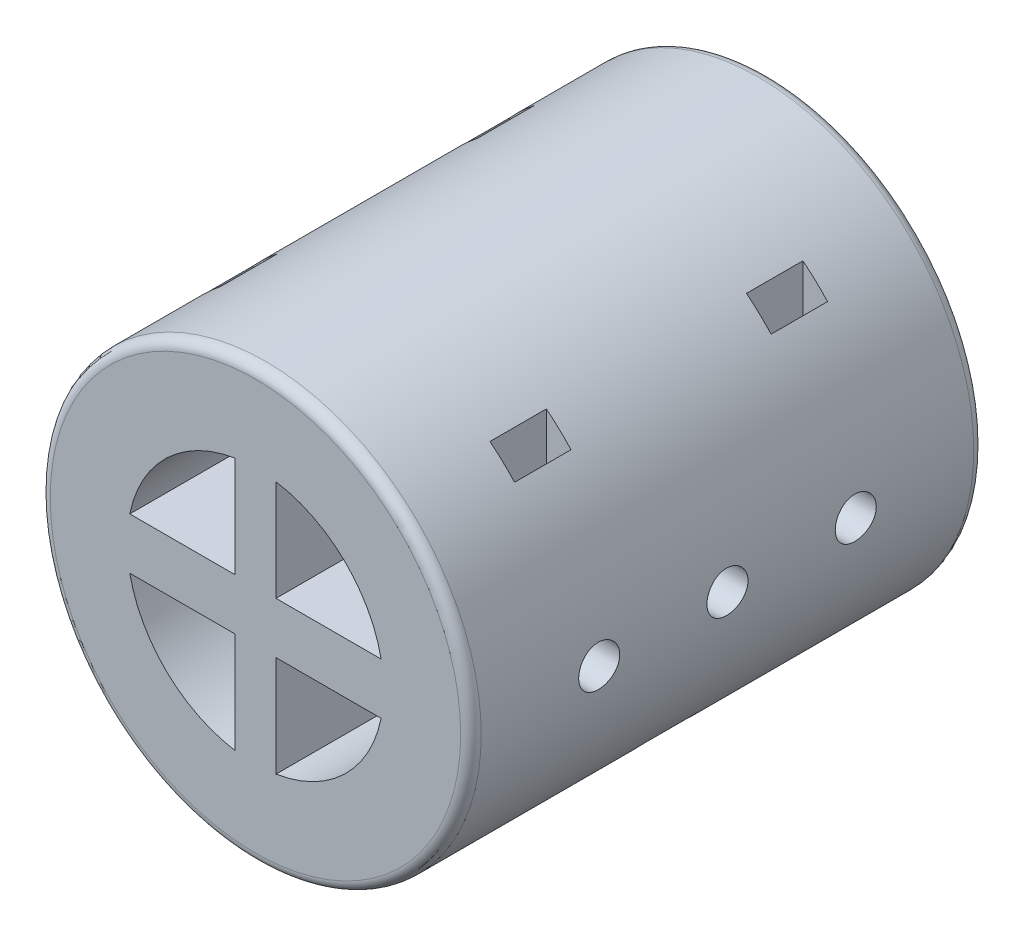
from build123d import *

# Parameters (mm, degrees)
SKETCH_1_R           = 21
EXTRUDE_1_DEPTH      = 50
FILLET_1_R           = 1
FILLET_2_R           = 1
SKETCH_2_R           = 2
CUT_EXTRUDE_1_DEPTH  = 69.593002559
CUT_EXTRUDE_START    = -5
CUT_EXTRUDE_2_DEPTH  = 2.4
CUT_EXTRUDE_9_DEPTH  = 59.154965466
SKETCH_6_W           = 2.4
SKETCH_6_H           = 5.5
CUT_EXTRUDE_10_DEPTH = 21
CUT_EXTRUDE_START_2  = -21
SKETCH_6_5_W         = 2.4
SKETCH_6_5_H         = 5.5
CUT_EXTRUDE_11_DEPTH = 21


with BuildPart() as part:
    # Эскиз1 → Бобышка-Вытянуть1 (new body)
    with BuildSketch(Plane.XY):
        Circle(SKETCH_1_R)
    extrude(amount=EXTRUDE_1_DEPTH)

    # Скругление1
    fillet_1_edges = [part.edges().sort_by_distance(p)[0] for p in [
        (-21, 0, 50),
    ]]
    fillet(fillet_1_edges, radius=FILLET_1_R)

    # Скругление2
    fillet_2_edges = [part.edges().sort_by_distance(p)[0] for p in [
        (-21, 0, 0),
    ]]
    fillet(fillet_2_edges, radius=FILLET_2_R)

    # Эскиз2 → Вырез-Вытянуть1 (cut, through all)
    with BuildSketch(Plane(origin=(21, 0, 0), x_dir=(0, 0, -1), z_dir=(1, 0, 0))):
        with Locations((-37.5, 0)):
            Circle(SKETCH_2_R)
        with Locations((-25, 0)):
            Circle(SKETCH_2_R)
        with Locations((-12.5, 0)):
            Circle(SKETCH_2_R)
    extrude(amount=-CUT_EXTRUDE_1_DEPTH, mode=Mode.SUBTRACT)

    # Эскиз3 → Вырез-Вытянуть2 (cut)
    with BuildSketch(Plane(origin=(21, 0, 0), x_dir=(0, 0, -1), z_dir=(1, 0, 0)).offset(CUT_EXTRUDE_START)):
        Polygon((-25, 3.175426481), (-27.75, 1.58771324), (-27.75, -1.58771324), (-25, -3.175426481), (-22.25, -1.58771324), (-22.25, 1.58771324), align=None)
        Polygon((-37.5, 3.175426481), (-40.25, 1.58771324), (-40.25, -1.58771324), (-37.5, -3.175426481), (-34.75, -1.58771324), (-34.75, 1.58771324), align=None)
        Polygon((-12.5, 3.175426481), (-15.25, 1.58771324), (-15.25, -1.58771324), (-12.5, -3.175426481), (-9.75, -1.58771324), (-9.75, 1.58771324), align=None)
    cut_extrude_2 = extrude(amount=-CUT_EXTRUDE_2_DEPTH, mode=Mode.SUBTRACT)

    # Зеркальное отражение1: Вырез-Вытянуть2 across plane
    add(cut_extrude_2.mirror(Plane(origin=(0, 0, 0), x_dir=(0, 0, 1), z_dir=(1, 0, 0))), mode=Mode.SUBTRACT)

    # Эскиз4 → Вырез-Вытянуть9 (cut, through all)
    with BuildSketch(Plane.XY.offset(50)):
        with BuildLine():
            Line((2, 12.338962679), (2, 2.5))
            Line((2, 2.5), (12.247448714, 2.5))
            ThreePointArc((12.247448714, 2.5), (8.657294344, 9.016720836), (2, 12.338962679))
        make_face()
        with BuildLine():
            Line((-2, 2.5), (-2, 12.338962679))
            ThreePointArc((-2, 12.338962679), (-8.657294344, 9.016720836), (-12.247448714, 2.5))
            Line((-12.247448714, 2.5), (-2, 2.5))
        make_face()
        with BuildLine():
            ThreePointArc((2, -12.338962679), (8.657294344, -9.016720836), (12.247448714, -2.5))
            Line((12.247448714, -2.5), (2, -2.5))
            Line((2, -2.5), (2, -12.338962679))
        make_face()
        with BuildLine():
            Line((-2, -2.5), (-12.247448714, -2.5))
            ThreePointArc((-12.247448714, -2.5), (-8.657294344, -9.016720836), (-2, -12.338962679))
            Line((-2, -12.338962679), (-2, -2.5))
        make_face()
    extrude(amount=-CUT_EXTRUDE_9_DEPTH, mode=Mode.SUBTRACT)

    # Эскиз6 → Вырез-Вытянуть10 (cut)
    with BuildSketch(Plane(origin=(0, 21, 0), x_dir=(1, 0, 0), z_dir=(0, 1, 0))):
        with Locations((14.3, -37.5)):
            Rectangle(SKETCH_6_W, SKETCH_6_H)
        with Locations((14.3, -12.5)):
            Rectangle(SKETCH_6_W, SKETCH_6_H)
    cut_extrude_10 = extrude(amount=-CUT_EXTRUDE_10_DEPTH, mode=Mode.SUBTRACT)

    # Эскиз6<5> → Вырез-Вытянуть11 (cut)
    with BuildSketch(Plane(origin=(0, 21, 0), x_dir=(1, 0, 0), z_dir=(0, 1, 0)).offset(CUT_EXTRUDE_START_2)):
        with Locations((14.3, -25)):
            Rectangle(SKETCH_6_5_W, SKETCH_6_5_H)
    cut_extrude_11 = extrude(amount=-CUT_EXTRUDE_11_DEPTH, mode=Mode.SUBTRACT)

    # Зеркальное отражение2: Вырез-Вытянуть10, Вырез-Вытянуть11 across plane
    add(cut_extrude_10.mirror(Plane(origin=(0, 0, 0), x_dir=(0, 0, 1), z_dir=(1, 0, 0))), mode=Mode.SUBTRACT)
    add(cut_extrude_11.mirror(Plane(origin=(0, 0, 0), x_dir=(0, 0, 1), z_dir=(1, 0, 0))), mode=Mode.SUBTRACT)


solid = part.part
